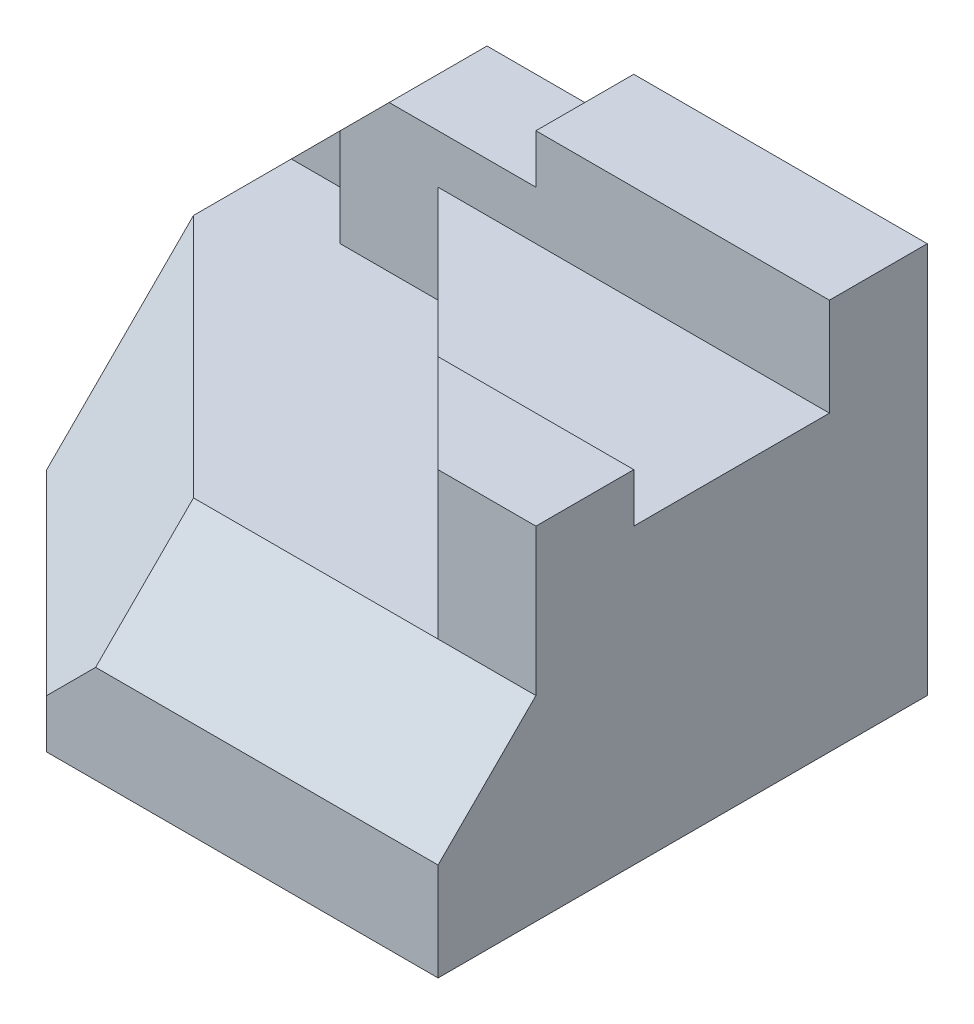
from build123d import *

# Parameters (mm, degrees)
SKETCH1_W           = 120
SKETCH1_H           = 80
BOSS_EXTRUDE1_DEPTH = 100
CUT_EXTRUDE1_DEPTH  = 100
CUT_EXTRUDE2_DEPTH  = 100
SKETCH4_W           = 120
SKETCH4_H           = 80
CUT_EXTRUDE3_DEPTH  = 100
CUT_EXTRUDE4_DEPTH  = 10
BOSS_EXTRUDE4_DEPTH = 20
BOSS_EXTRUDE5_DEPTH = 10
CUT_EXTRUDE8_DEPTH  = 156
CUT_EXTRUDE10_DEPTH = 156
CUT_EXTRUDE11_DEPTH = 156
CUT_EXTRUDE12_DEPTH = 156


with BuildPart() as part:
    # Sketch1 → Boss-Extrude1 (new body)
    with BuildSketch(Plane.XY):
        with Locations((60, 40)):
            Rectangle(SKETCH1_W, SKETCH1_H)
    extrude(amount=BOSS_EXTRUDE1_DEPTH)

    # Sketch2 → Cut-Extrude1 (cut)
    with BuildSketch(Plane(origin=(0, 80, 0), x_dir=(1, 0, 0), z_dir=(0, 1, 0))):
        Polygon((0, -60), (40, -100), (0, -100), align=None)
    extrude(amount=-CUT_EXTRUDE1_DEPTH, mode=Mode.SUBTRACT)

    # Sketch3 → Cut-Extrude2 (cut)
    with BuildSketch(Plane(origin=(0, 0, 0), x_dir=(-1, 0, 0), z_dir=(0, 0, -1))):
        Polygon((0, 40), (-30, 70), (-60, 70), (-60, 80), (0, 80), align=None)
    extrude(amount=-CUT_EXTRUDE2_DEPTH, mode=Mode.SUBTRACT)

    # Sketch4 → Cut-Extrude3 (cut)
    with BuildSketch(Plane(origin=(0, 40, 0), x_dir=(1, 0, 0), z_dir=(0, 1, 0))):
        with Locations((60, -60)):
            Rectangle(SKETCH4_W, SKETCH4_H)
    extrude(amount=CUT_EXTRUDE3_DEPTH, mode=Mode.SUBTRACT)

    # Sketch5 → Cut-Extrude4 (cut)
    with BuildSketch(Plane.XY.offset(20)):
        Polygon((20, 40), (20, 60), (0, 40), align=None)
    extrude(amount=-CUT_EXTRUDE4_DEPTH, mode=Mode.SUBTRACT)

    # Sketch6 → Boss-Extrude4 (add)
    with BuildSketch(Plane(origin=(0, 40, 0), x_dir=(1, 0, 0), z_dir=(0, 1, 0))):
        Polygon((40, -20), (120, -20), (120, -80), (100, -80), align=None)
    extrude(amount=BOSS_EXTRUDE4_DEPTH)

    # Sketch8 → Boss-Extrude5 (add)
    with BuildSketch(Plane(origin=(0, 60, 0), x_dir=(1, 0, 0), z_dir=(0, 1, 0))):
        Polygon((80, -60), (120, -60), (120, -80), (100, -80), align=None)
    extrude(amount=BOSS_EXTRUDE5_DEPTH)

    # Sketch9 → Cut-Extrude8 (cut)
    with BuildSketch(Plane(origin=(120, 0, 0), x_dir=(0, 0, -1), z_dir=(1, 0, 0))):
        Polygon((-100, 40), (-80, 40), (-100, 20), align=None)
    extrude(amount=-CUT_EXTRUDE8_DEPTH, mode=Mode.SUBTRACT)

    # Sketch13 → Cut-Extrude10 (cut)
    with BuildSketch(Plane(origin=(-23.333333333, 23.333333333, 23.333333333), x_dir=(0.816496581, 0.40824829, 0.40824829), z_dir=(-0.577350269, 0.577350269, 0.577350269))):
        Polygon((28.577380332, 7.071067812), (28.577380332, -35.355339059), (77.567175188, -63.639610307), (89.814623902, -28.284271247), align=None)
    extrude(amount=CUT_EXTRUDE10_DEPTH, mode=Mode.SUBTRACT)

    # Sketch14 → Cut-Extrude11 (cut)
    with BuildSketch(Plane(origin=(72.619047619, 14.523809524, 58.095238095), x_dir=(-0.605227533, -0.121045507, 0.786795792), z_dir=(-0.77151675, -0.15430335, -0.6172134))):
        Polygon((53.260022875, 1.961161351), (27.840466503, 29.417420271), (51.671300602, 13.237839122), align=None)
    extrude(amount=-CUT_EXTRUDE11_DEPTH, mode=Mode.SUBTRACT)

    # Sketch15 → Cut-Extrude12 (cut)
    with BuildSketch(Plane(origin=(-33.221457258, 0.897877223, 41.302352266), x_dir=(-0.779285755, -0.013620016, -0.626520716), z_dir=(0.626668742, -0.016936993, -0.779101679))):
        Polygon((-94.306519852, 17.821876236), (-92.355669011, 19.098748466), (-93.959701924, 7.824238347), align=None)
    extrude(amount=-CUT_EXTRUDE12_DEPTH, mode=Mode.SUBTRACT)


solid = part.part
